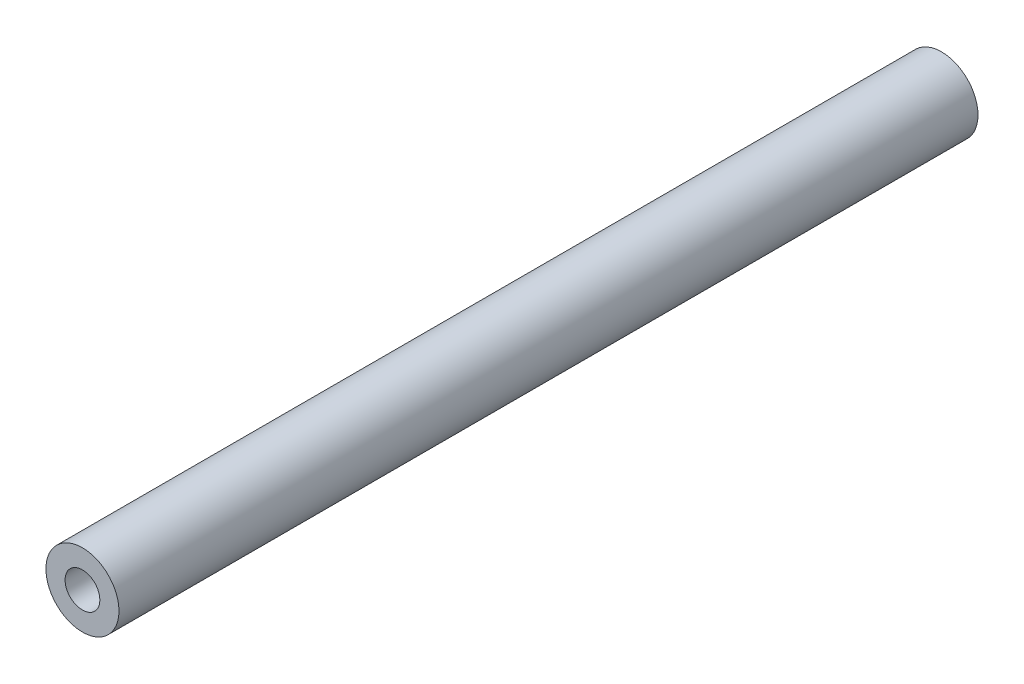
from build123d import *

# Parameters (mm, degrees)
ESBO_O1_R                = 2.1
ESBO_O1_R_2              = 1
RESSALTO_EXTRUS_O1_DEPTH = 49.4


with BuildPart() as part:
    # Esboço1 → Ressalto-extrusão1 (new body)
    with BuildSketch(Plane.XY):
        Circle(ESBO_O1_R)
        Circle(ESBO_O1_R_2, mode=Mode.SUBTRACT)
    extrude(amount=RESSALTO_EXTRUS_O1_DEPTH)


solid = part.part
